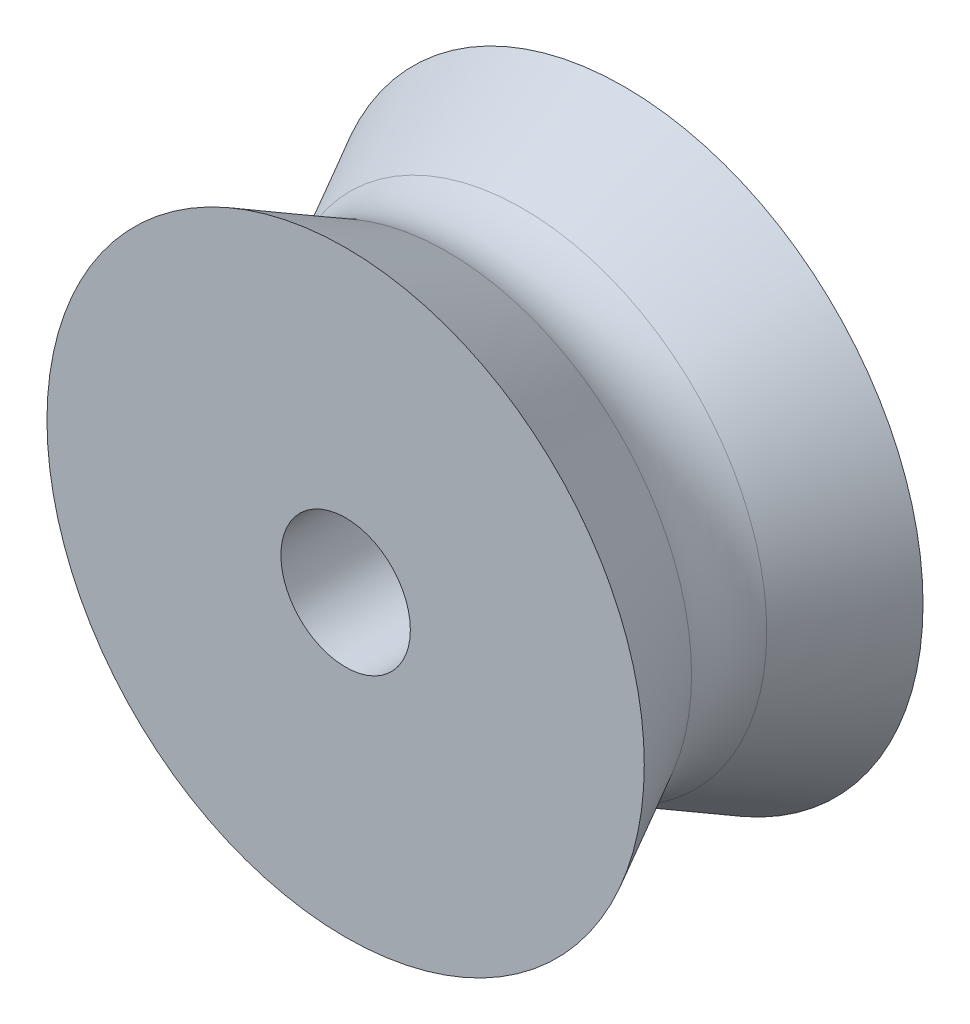
from build123d import *


with BuildPart() as part:
    # Sketch4 → Revolve1 (revolve)
    with BuildSketch(Plane(origin=(0, 0, 0), x_dir=(1, 0, 0), z_dir=(0, 1, 0))):
        with BuildLine():
            Line((3.25, 0), (3.25, 14))
            Line((3.25, 14), (15, 14))
            Line((15, 14), (12.261903027, 8.88888565))
            ThreePointArc((12.261903027, 8.88888565), (11.787822907, 7), (12.261903027, 5.11111435))
            Line((12.261903027, 5.11111435), (15, 0))
            Line((15, 0), (3.25, 0))
        make_face()
    revolve(axis=Axis((0, 0, 0), (0, 0, -1)))


solid = part.part
